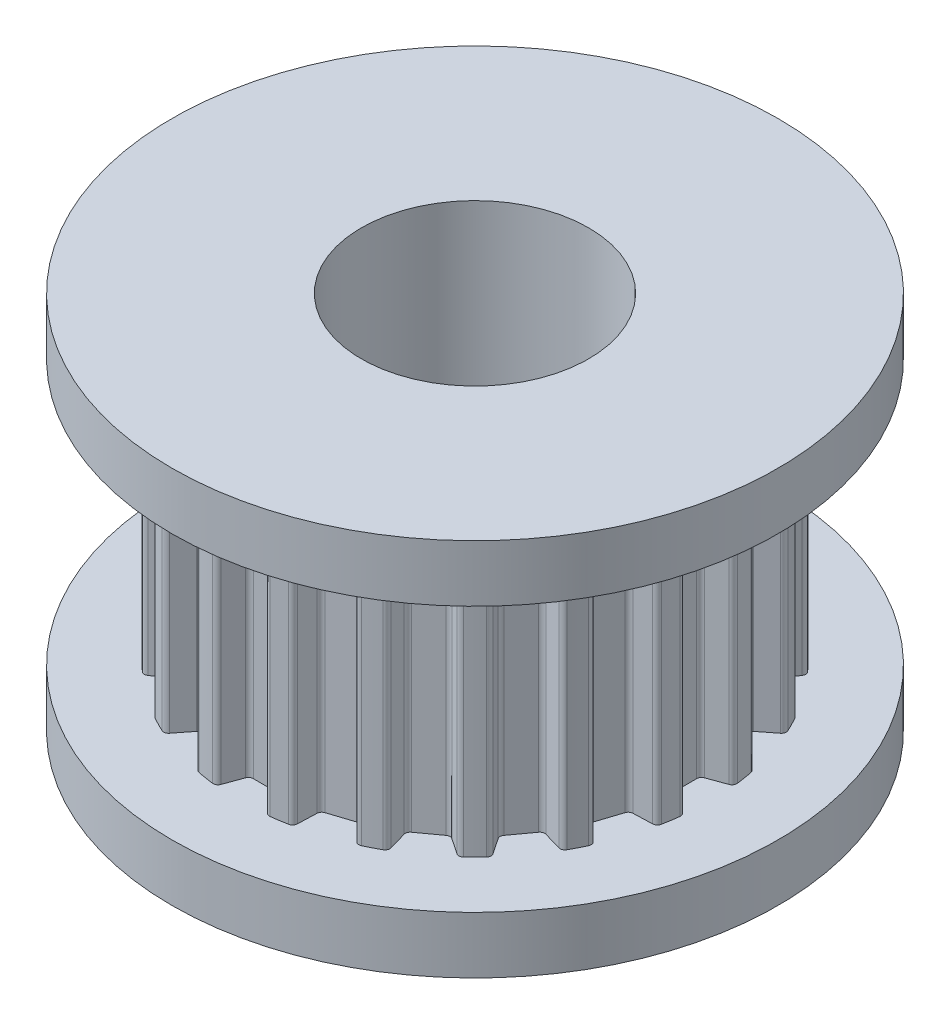
from build123d import *

# Parameters (mm, degrees)
EXTRUDE_1_DEPTH                  = 3.5
EXTRUDE_1_DEPTH_BACK             = 3.5
SKETCH_1_R                       = 6.215
CUT_EXTRUDE_1_DEPTH              = 12.23621155
FILLET_1_R                       = 0.13
PATTERN_CIRCULAR_1_COUNT         = 20
FILLET_1_OF_PATTERN_CIRCULAR_1_R = 0.13
SKETCH_3_R                       = 8
EXTRUDE_2_DEPTH                  = 1.5
EXTRUDE_START                    = 1.5
SKETCH_4_R                       = 8
EXTRUDE_3_DEPTH                  = 1.5
CUT_EXTRUDE_2_DEPTH              = 16.099668871
CUT_EXTRUDE_2_DEPTH_BACK         = 16.099668871
SKETCH_5_R                       = 3


with BuildPart() as part:
    # 草圖1 → 填料-伸長1 (new, two sides: drawn at the far end of the back side and taken through both)
    with BuildSketch(Plane(origin=(0, 0, 0), x_dir=(1, 0, 0), z_dir=(0, 1, 0)).offset(-EXTRUDE_1_DEPTH_BACK)):
        Circle(SKETCH_1_R)
    extrude(amount=EXTRUDE_1_DEPTH + EXTRUDE_1_DEPTH_BACK)

    # 草圖2 → 除料-伸長1 (cut, through all)
    with BuildSketch(Plane.XZ.offset(3.5)):
        with BuildLine():
            ThreePointArc((0.658409965, 6.180025997), (0, 6.215), (-0.658409965, 6.180025997))
            Line((-0.658409965, 6.180025997), (-0.42, 5.525))
            Line((-0.42, 5.525), (0.42, 5.525))
            Line((0.42, 5.525), (0.658409965, 6.180025997))
        make_face()
    cut_extrude_1 = extrude(amount=-CUT_EXTRUDE_1_DEPTH, mode=Mode.SUBTRACT)

    # 圓角1
    fillet_1_edges = [part.edges().sort_by_distance(p)[0] for p in [
        (-0.658409965, 0, 6.180025997),
        (0.658409965, 0, 6.180025997),
        (0.42, 0, 5.525),
        (-0.42, 0, 5.525),
    ]]
    fillet(fillet_1_edges, radius=FILLET_1_R)

    # 環狀複製排列1: 除料-伸長1 ×20 about axis
    pattern_circular_1_axis = Axis((0, -3.5, 0), (0, 1, 0))
    for i in range(1, PATTERN_CIRCULAR_1_COUNT):
        add(cut_extrude_1.rotate(pattern_circular_1_axis, i * 360 / PATTERN_CIRCULAR_1_COUNT), mode=Mode.SUBTRACT)

    # 圓角1 of 環狀複製排列1
    fillet_1_of_pattern_circular_1_edges = [part.edges().sort_by_distance(p)[0] for p in [
        (1.283547971, 0, 6.081013863),
        (2.535918147, 0, 5.674094126),
        (2.106762631, 0, 5.124800115),
        (1.307875157, 0, 5.38437439),
        (3.099863288, 0, 5.386749724),
        (4.165192991, 0, 4.612742389),
        (3.587300657, 0, 4.222949088),
        (2.907726381, 0, 4.7166887),
        (4.612742389, 0, 4.165192991),
        (5.386749724, 0, 3.099863288),
        (4.7166887, 0, 2.907726381),
        (4.222949088, 0, 3.587300657),
        (5.674094126, 0, 2.535918147),
        (6.081013863, 0, 1.283547971),
        (5.38437439, 0, 1.307875157),
        (5.124800115, 0, 2.106762631),
        (6.180025997, 0, 0.658409965),
        (6.180025997, 0, -0.658409965),
        (5.525, 0, -0.42),
        (5.525, 0, 0.42),
        (6.081013863, 0, -1.283547971),
        (5.674094126, 0, -2.535918147),
        (5.124800115, 0, -2.106762631),
        (5.38437439, 0, -1.307875157),
        (5.386749724, 0, -3.099863288),
        (4.612742389, 0, -4.165192991),
        (4.222949088, 0, -3.587300657),
        (4.7166887, 0, -2.907726381),
        (4.165192991, 0, -4.612742389),
        (3.099863288, 0, -5.386749724),
        (2.907726381, 0, -4.7166887),
        (3.587300657, 0, -4.222949088),
        (2.535918147, 0, -5.674094126),
        (1.283547971, 0, -6.081013863),
        (1.307875157, 0, -5.38437439),
        (2.106762631, 0, -5.124800115),
        (0.658409965, 0, -6.180025997),
        (-0.658409965, 0, -6.180025997),
        (-0.42, 0, -5.525),
        (0.42, 0, -5.525),
        (-1.283547971, 0, -6.081013863),
        (-2.535918147, 0, -5.674094126),
        (-2.106762631, 0, -5.124800115),
        (-1.307875157, 0, -5.38437439),
        (-3.099863288, 0, -5.386749724),
        (-4.165192991, 0, -4.612742389),
        (-3.587300657, 0, -4.222949088),
        (-2.907726381, 0, -4.7166887),
        (-4.612742389, 0, -4.165192991),
        (-5.386749724, 0, -3.099863288),
        (-4.7166887, 0, -2.907726381),
        (-4.222949088, 0, -3.587300657),
        (-5.674094126, 0, -2.535918147),
        (-6.081013863, 0, -1.283547971),
        (-5.38437439, 0, -1.307875157),
        (-5.124800115, 0, -2.106762631),
        (-6.180025997, 0, -0.658409965),
        (-6.180025997, 0, 0.658409965),
        (-5.525, 0, 0.42),
        (-5.525, 0, -0.42),
        (-6.081013863, 0, 1.283547971),
        (-5.674094126, 0, 2.535918147),
        (-5.124800115, 0, 2.106762631),
        (-5.38437439, 0, 1.307875157),
        (-5.386749724, 0, 3.099863288),
        (-4.612742389, 0, 4.165192991),
        (-4.222949088, 0, 3.587300657),
        (-4.7166887, 0, 2.907726381),
        (-4.165192991, 0, 4.612742389),
        (-3.099863288, 0, 5.386749724),
        (-2.907726381, 0, 4.7166887),
        (-3.587300657, 0, 4.222949088),
        (-2.535918147, 0, 5.674094126),
        (-1.283547971, 0, 6.081013863),
        (-1.307875157, 0, 5.38437439),
        (-2.106762631, 0, 5.124800115),
    ]]
    fillet(fillet_1_of_pattern_circular_1_edges, radius=FILLET_1_OF_PATTERN_CIRCULAR_1_R)

    # 草圖3 → 填料-伸長2 (add)
    with BuildSketch(Plane(origin=(0, 3.5, 0), x_dir=(1, 0, 0), z_dir=(0, 1, 0))):
        Circle(SKETCH_3_R)
    extrude(amount=EXTRUDE_2_DEPTH)

    # 草圖4 → 填料-伸長3 (add)
    with BuildSketch(Plane.XZ.offset(3.5).offset(EXTRUDE_START)):
        Circle(SKETCH_4_R)
    extrude(amount=-EXTRUDE_3_DEPTH)

    # 草圖5 → 除料-伸長2 (cut, two sides: drawn at the far end of the back side and taken through both)
    with BuildSketch(Plane.XZ.offset(5).offset(-CUT_EXTRUDE_2_DEPTH_BACK)):
        Circle(SKETCH_5_R)
    extrude(amount=CUT_EXTRUDE_2_DEPTH + CUT_EXTRUDE_2_DEPTH_BACK, mode=Mode.SUBTRACT)


solid = part.part
